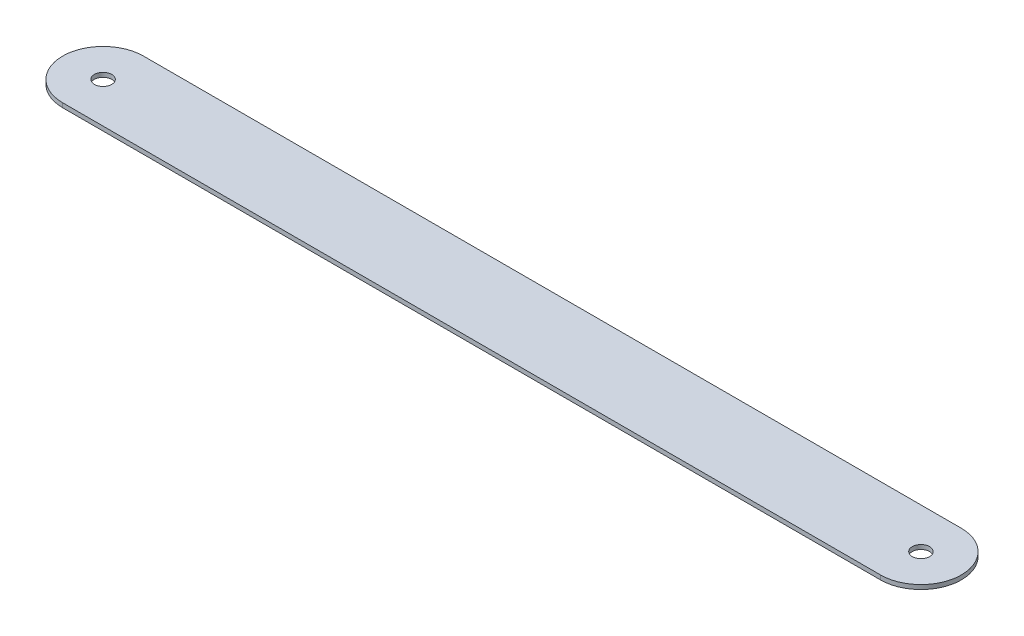
from build123d import *

# Parameters (mm, degrees)
SKETCH1_R           = 3
BOSS_EXTRUDE1_DEPTH = 1.5


with BuildPart() as part:
    # Sketch1 → Boss-Extrude1 (new body)
    with BuildSketch(Plane(origin=(0, 0, 0), x_dir=(1, 0, 0), z_dir=(0, 1, 0))):
        with BuildLine():
            Line((0, 14), (283.23, 14))
            ThreePointArc((283.23, 14), (297.23, 0), (283.23, -14))
            Line((283.23, -14), (0, -14))
            ThreePointArc((0, -14), (-14, 0), (0, 14))
        make_face()
        Circle(SKETCH1_R, mode=Mode.SUBTRACT)
        with Locations((283.23, 0)):
            Circle(SKETCH1_R, mode=Mode.SUBTRACT)
    extrude(amount=BOSS_EXTRUDE1_DEPTH)


solid = part.part
